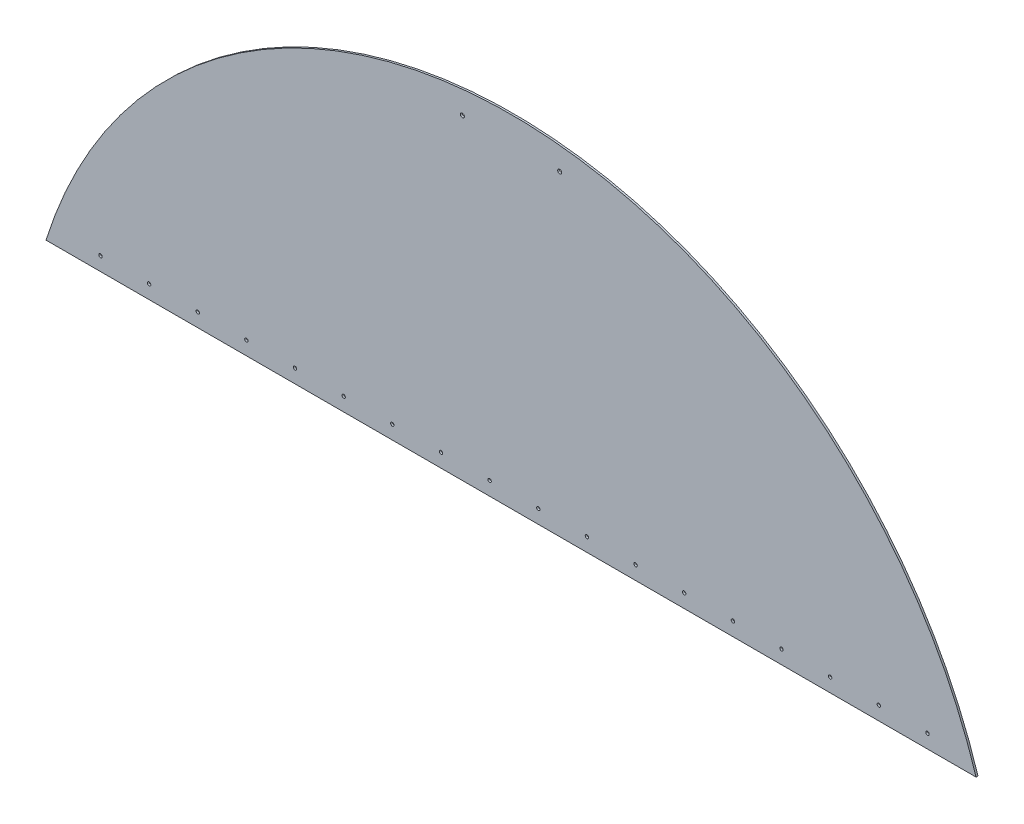
from build123d import *

# Parameters (mm, degrees)
BOSS_EXTRUDE1_DEPTH = 1.98374
SKETCH2_R           = 1.778
CUT_EXTRUDE1_DEPTH  = 25.4
LPATTERN1_COUNT     = 18
LPATTERN1_PITCH     = 50.8
SKETCH3_R           = 2.0955
CUT_EXTRUDE2_DEPTH  = 1.98374


with BuildPart() as part:
    # Sketch1 → Boss-Extrude1 (new body)
    with BuildSketch(Plane.XY):
        with BuildLine():
            Line((-485.639445359, 152.4), (485.639445359, 152.4))
            ThreePointArc((485.639445359, 152.4), (0, 508.9906), (-485.639445359, 152.4))
        make_face()
    extrude(amount=BOSS_EXTRUDE1_DEPTH)

    # Sketch2 → Cut-Extrude1 (cut)
    with BuildSketch(Plane.XY.offset(1.98374)):
        with Locations((434.839445359, 166.6875)):
            Circle(SKETCH2_R)
    cut_extrude1 = extrude(amount=-CUT_EXTRUDE1_DEPTH, mode=Mode.SUBTRACT)

    # LPattern1: Cut-Extrude1 ×18
    with Locations(*[(-i * LPATTERN1_PITCH, 0, 0) for i in range(1, LPATTERN1_COUNT)]):
        add(cut_extrude1, mode=Mode.SUBTRACT)

    # Sketch3 → Cut-Extrude2 (cut)
    with BuildSketch(Plane.XY.offset(1.98374)):
        with Locations((-50.8, 482.6)):
            Circle(SKETCH3_R)
        with Locations((50.8, 482.6)):
            Circle(SKETCH3_R)
    extrude(amount=-CUT_EXTRUDE2_DEPTH, mode=Mode.SUBTRACT)


solid = part.part
